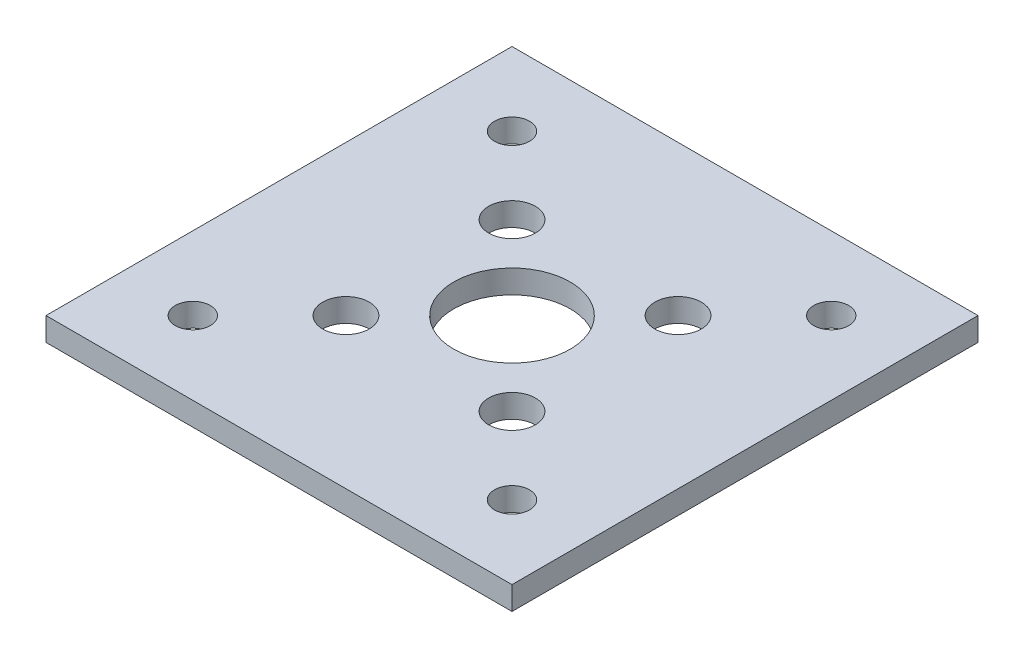
from build123d import *

# Parameters (mm, degrees)
SKETCH1_W           = 63.5
SKETCH1_H           = 63.5
BOSS_EXTRUDE1_DEPTH = 3.175
SKETCH2_R           = 3.175
SKETCH2_R_2         = 7.9375
SKETCH2_R_3         = 2.38125
CUT_EXTRUDE1_DEPTH  = 4.175


with BuildPart() as part:
    # Sketch1 → Boss-Extrude1 (new body)
    with BuildSketch(Plane(origin=(0, 0, 0), x_dir=(1, 0, 0), z_dir=(0, 1, 0))):
        Rectangle(SKETCH1_W, SKETCH1_H)
    extrude(amount=BOSS_EXTRUDE1_DEPTH)

    # Sketch2 → Cut-Extrude1 (cut, through all)
    with BuildSketch(Plane(origin=(0, 3.175, 0), x_dir=(1, 0, 0), z_dir=(0, 1, 0))):
        with Locations((11.313708499, 11.313708499)):
            Circle(SKETCH2_R)
        with Locations((11.313708499, -11.313708499)):
            Circle(SKETCH2_R)
        with Locations((-11.313708499, -11.313708499)):
            Circle(SKETCH2_R)
        with Locations((-11.313708499, 11.313708499)):
            Circle(SKETCH2_R)
        Circle(SKETCH2_R_2)
        with Locations((-21.75, -21.75)):
            Circle(SKETCH2_R_3)
        with Locations((21.75, -21.75)):
            Circle(SKETCH2_R_3)
        with Locations((21.75, 21.75)):
            Circle(SKETCH2_R_3)
        with Locations((-21.75, 21.75)):
            Circle(SKETCH2_R_3)
    extrude(amount=-CUT_EXTRUDE1_DEPTH, mode=Mode.SUBTRACT)


solid = part.part
